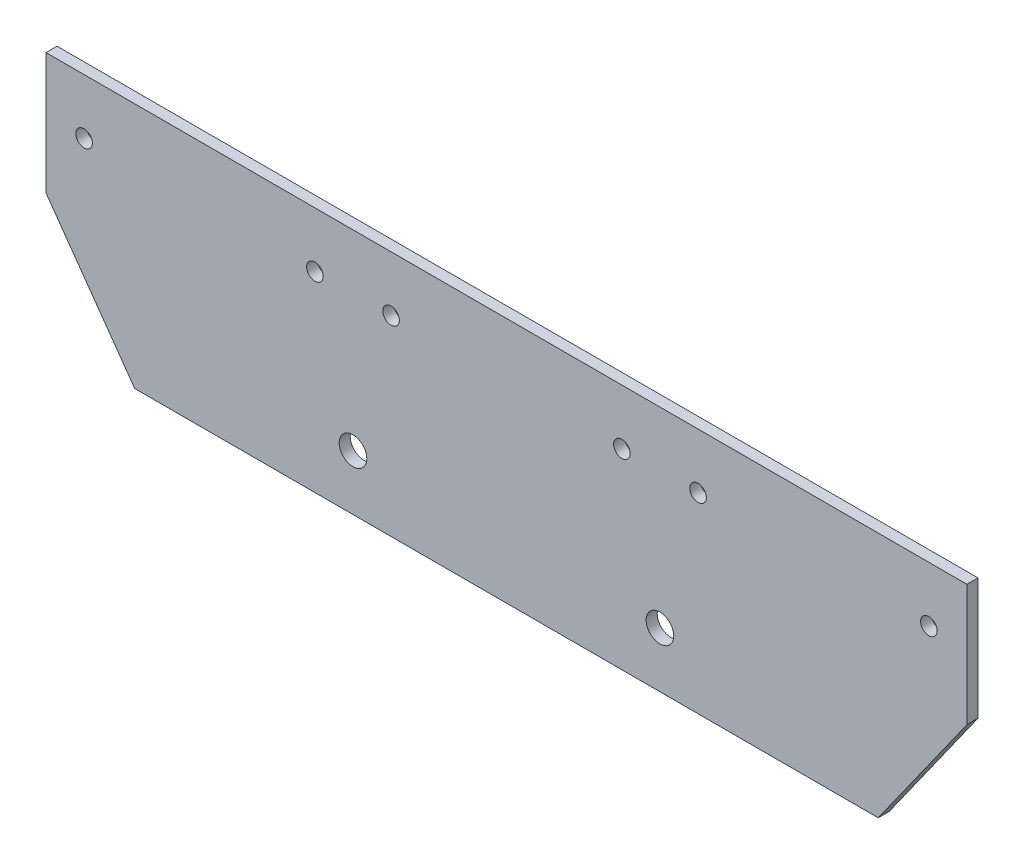
from build123d import *

# Parameters (mm, degrees)
SKETCH1_W           = 55.560809748
SKETCH1_H           = 22
SKETCH1_R           = 1.5
BOSS_EXTRUDE1_DEPTH = 2
SKETCH3_R           = 2.5
CUT_EXTRUDE1_DEPTH  = 2


with BuildPart() as part:
    # Sketch1 → Boss-Extrude1 (new body)
    # profile 1 of 4: a face of its own
    with BuildSketch(Plane.XY):
        Polygon((-62.402927025, 55.272853248), (-46.347522151, 32.642853248), (-22.897522151, 32.642853248), (88.224097345, 32.642853248), (104.279502219, 55.272853248), (48.718692471, 55.272853248), (-6.842117277, 55.272853248), align=None)
    # profile 2 of 4: a face of its own
    with BuildSketch(Plane.XY):
        with Locations((-34.622522151, 66.272853248)):
            Rectangle(SKETCH1_W, SKETCH1_H)
        with Locations((-55.512724588, 67.272853248)):
            Circle(SKETCH1_R, mode=Mode.SUBTRACT)
        with Locations((-13.732319714, 67.272853248)):
            Circle(SKETCH1_R, mode=Mode.SUBTRACT)
    # profile 3 of 4: a face of its own
    with BuildSketch(Plane.XY):
        with Locations((20.938287597, 66.272853248)):
            Rectangle(SKETCH1_W, SKETCH1_H)
        with Locations((0.04808516, 67.272853248)):
            Circle(SKETCH1_R, mode=Mode.SUBTRACT)
        with Locations((41.828490034, 67.272853248)):
            Circle(SKETCH1_R, mode=Mode.SUBTRACT)
    # profile 4 of 4: a face of its own
    with BuildSketch(Plane.XY):
        with Locations((76.499097345, 66.272853248)):
            Rectangle(SKETCH1_W, SKETCH1_H)
        with Locations((55.608894908, 67.272853248)):
            Circle(SKETCH1_R, mode=Mode.SUBTRACT)
        with Locations((97.389299782, 67.272853248)):
            Circle(SKETCH1_R, mode=Mode.SUBTRACT)
    extrude(amount=BOSS_EXTRUDE1_DEPTH)

    # Sketch3 → Cut-Extrude1 (cut)
    with BuildSketch(Plane(origin=(0, 0, 0), x_dir=(-1, 0, 0), z_dir=(0, 0, -1))):
        with Locations((-48.718692471, 42.642853248)):
            Circle(SKETCH3_R)
        with Locations(Location((6.842117277, 42.642853248, 0), (0, 0, 180))):
            Circle(SKETCH3_R)
    extrude(amount=-CUT_EXTRUDE1_DEPTH, mode=Mode.SUBTRACT)


solid = part.part
